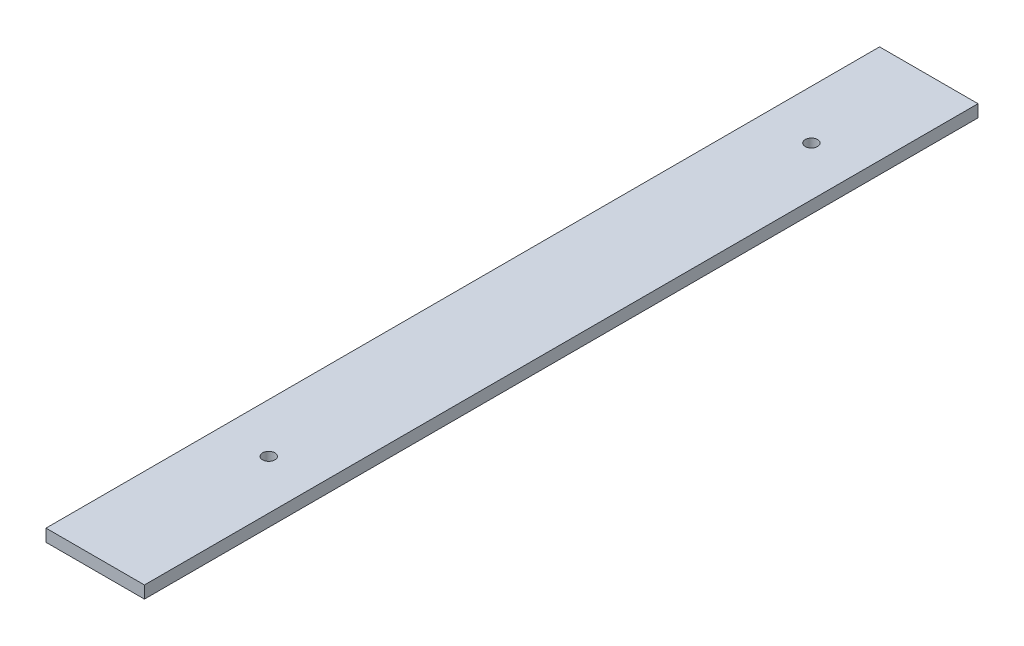
from build123d import *

# Parameters (mm, degrees)
SKETCH4_W             = 200
SKETCH4_H             = 2933.573874127
SKETCH4_R             = 12.5
BOSS_EXTRUDE1_DEPTH   = 25
SKETCH4_H_2           = 2891.000919938
BOSS_EXTRUDE1_2_DEPTH = 25
SKETCH4_H_3           = 2656.8496719
BOSS_EXTRUDE1_3_DEPTH = 25
SKETCH4_H_4           = 2167.26069873
BOSS_EXTRUDE1_4_DEPTH = 25
SKETCH4_H_5           = 1693.636583381
BOSS_EXTRUDE1_5_DEPTH = 25
SKETCH5_W             = 6063.042757238
SKETCH5_H             = 4952.659926698
CUT_EXTRUDE1_DEPTH    = 26


with BuildPart() as part:
    # Sketch4 → Boss-Extrude1 (new body)
    with BuildSketch(Plane(origin=(0, 0, 0), x_dir=(1, 0, 0), z_dir=(0, 1, 0))):
        with Locations((23132.944645813, -11409.369811035)):
            Rectangle(SKETCH4_W, SKETCH4_H)
        with Locations((23132.944645813, -12678.089615367)):
            Circle(SKETCH4_R, mode=Mode.SUBTRACT)
        with Locations((23132.944645813, -10181.030459334)):
            Circle(SKETCH4_R, mode=Mode.SUBTRACT)
    extrude(amount=BOSS_EXTRUDE1_DEPTH)


with BuildPart() as body_2:
    # Sketch4 → Boss-Extrude1 2 (new body)
    with BuildSketch(Plane(origin=(0, 0, 0), x_dir=(1, 0, 0), z_dir=(0, 1, 0))):
        with Locations((22032.944645813, -11388.083333941)):
            Rectangle(SKETCH4_W, SKETCH4_H_2)
        with Locations((22032.944645813, -12621.228285175)):
            Circle(SKETCH4_R, mode=Mode.SUBTRACT)
        with Locations((22032.944645813, -10181.030459334)):
            Circle(SKETCH4_R, mode=Mode.SUBTRACT)
    extrude(amount=BOSS_EXTRUDE1_2_DEPTH)


with BuildPart() as body_3:
    # Sketch4 → Boss-Extrude1 3 (new body)
    with BuildSketch(Plane(origin=(0, 0, 0), x_dir=(1, 0, 0), z_dir=(0, 1, 0))):
        with Locations((20832.944645813, -11271.007709922)):
            Rectangle(SKETCH4_W, SKETCH4_H_3)
        with Locations((20832.944645813, -12348.754240871)):
            Circle(SKETCH4_R, mode=Mode.SUBTRACT)
        with Locations((20832.944645813, -10181.030459334)):
            Circle(SKETCH4_R, mode=Mode.SUBTRACT)
    extrude(amount=BOSS_EXTRUDE1_3_DEPTH)


with BuildPart() as body_4:
    # Sketch4 → Boss-Extrude1 4 (new body)
    with BuildSketch(Plane(origin=(0, 0, 0), x_dir=(1, 0, 0), z_dir=(0, 1, 0))):
        with Locations((19632.944645813, -11026.213223337)):
            Rectangle(SKETCH4_W, SKETCH4_H_4)
        with Locations((19632.944645813, -11826.915448153)):
            Circle(SKETCH4_R, mode=Mode.SUBTRACT)
        with Locations((19632.944645813, -10181.030459334)):
            Circle(SKETCH4_R, mode=Mode.SUBTRACT)
    extrude(amount=BOSS_EXTRUDE1_4_DEPTH)


with BuildPart() as body_5:
    # Sketch4 → Boss-Extrude1 5 (new body)
    with BuildSketch(Plane(origin=(0, 0, 0), x_dir=(1, 0, 0), z_dir=(0, 1, 0))):
        with Locations((18802.944645813, -10789.401165663)):
            Rectangle(SKETCH4_W, SKETCH4_H_5)
        with Locations((18802.944645813, -11283.669778774)):
            Circle(SKETCH4_R, mode=Mode.SUBTRACT)
        with Locations((18802.944645813, -10181.030459334)):
            Circle(SKETCH4_R, mode=Mode.SUBTRACT)
    extrude(amount=BOSS_EXTRUDE1_5_DEPTH)


with BuildPart() as cut_extrude1_tool:
    # Sketch5 → Cut-Extrude1 (new body, through all)
    with BuildSketch(Plane(origin=(0, 0, 0), x_dir=(1, 0, 0), z_dir=(0, 1, 0))):
        with Locations((22113.577724943, -11321.244189564)):
            Rectangle(SKETCH5_W, SKETCH5_H)
    extrude(amount=CUT_EXTRUDE1_DEPTH)


with BuildPart() as part_1:
    add(part.part)

    # Cut-Extrude1: cut by cut_extrude1_tool
    add(cut_extrude1_tool.part, mode=Mode.SUBTRACT)


with BuildPart() as body_2_1:
    add(body_2.part)

    # Cut-Extrude1: cut by cut_extrude1_tool
    add(cut_extrude1_tool.part, mode=Mode.SUBTRACT)


with BuildPart() as body_3_1:
    add(body_3.part)

    # Cut-Extrude1: cut by cut_extrude1_tool
    add(cut_extrude1_tool.part, mode=Mode.SUBTRACT)


with BuildPart() as body_4_1:
    add(body_4.part)

    # Cut-Extrude1: cut by cut_extrude1_tool
    add(cut_extrude1_tool.part, mode=Mode.SUBTRACT)


solid = body_5.part
